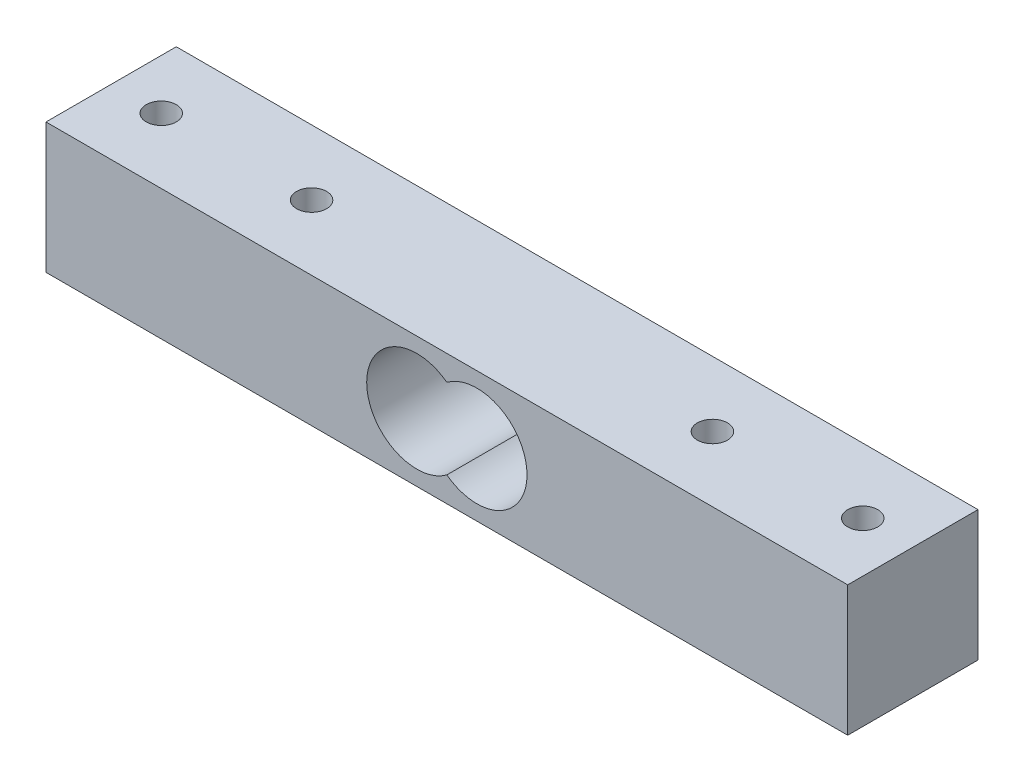
from build123d import *

# Parameters (mm, degrees)
SKETCH1_W               = 80
SKETCH1_H               = 13
BOSS_EXTRUDE1_DEPTH     = 13
CUT_EXTRUDE1_DEPTH      = 7.5
CUT_EXTRUDE1_DEPTH_BACK = 7.5
CUT_EXTRUDE2_REACH      = 15
SKETCH4_R               = 1.5


with BuildPart() as part:
    # Sketch1 → Boss-Extrude1 (new body)
    with BuildSketch(Plane(origin=(0, 0, 0), x_dir=(1, 0, 0), z_dir=(0, 1, 0))):
        Rectangle(SKETCH1_W, SKETCH1_H)
    extrude(amount=BOSS_EXTRUDE1_DEPTH)

    # Sketch3 → Cut-Extrude1 (cut, two sides)
    with BuildSketch(Plane.XY) as cut_extrude1_sk:
        with BuildLine():
            ThreePointArc((0, 2.5), (8, 6.5), (0, 10.5))
            ThreePointArc((0, 10.5), (-8, 6.5), (0, 2.5))
        make_face()
    extrude(amount=CUT_EXTRUDE1_DEPTH, mode=Mode.SUBTRACT)
    extrude(cut_extrude1_sk.sketch, amount=-CUT_EXTRUDE1_DEPTH_BACK, mode=Mode.SUBTRACT)

    # Sketch4 → Cut-Extrude2 (cut, up to next)
    with BuildSketch(Plane(origin=(0, 13, 0), x_dir=(1, 0, 0), z_dir=(0, 1, 0)), mode=Mode.PRIVATE) as cut_extrude2_sk1:
        with Locations((-35, 0)):
            Circle(SKETCH4_R)
    cut_extrude2_tool1 = extrude(cut_extrude2_sk1.sketch, amount=-CUT_EXTRUDE2_REACH, mode=Mode.PRIVATE) & part.part
    add(cut_extrude2_tool1.solids().sort_by_distance((-35, 13, 0))[0], mode=Mode.SUBTRACT)
    # Sketch4 → Cut-Extrude2 (cut, up to next)
    with BuildSketch(Plane(origin=(0, 13, 0), x_dir=(1, 0, 0), z_dir=(0, 1, 0)), mode=Mode.PRIVATE) as cut_extrude2_sk2:
        with Locations((-20, 0)):
            Circle(SKETCH4_R)
    cut_extrude2_tool2 = extrude(cut_extrude2_sk2.sketch, amount=-CUT_EXTRUDE2_REACH, mode=Mode.PRIVATE) & part.part
    add(cut_extrude2_tool2.solids().sort_by_distance((-20, 13, 0))[0], mode=Mode.SUBTRACT)
    # Sketch4 → Cut-Extrude2 (cut, up to next)
    with BuildSketch(Plane(origin=(0, 13, 0), x_dir=(1, 0, 0), z_dir=(0, 1, 0)), mode=Mode.PRIVATE) as cut_extrude2_sk3:
        with Locations((20, 0)):
            Circle(SKETCH4_R)
    cut_extrude2_tool3 = extrude(cut_extrude2_sk3.sketch, amount=-CUT_EXTRUDE2_REACH, mode=Mode.PRIVATE) & part.part
    add(cut_extrude2_tool3.solids().sort_by_distance((20, 13, 0))[0], mode=Mode.SUBTRACT)
    # Sketch4 → Cut-Extrude2 (cut, up to next)
    with BuildSketch(Plane(origin=(0, 13, 0), x_dir=(1, 0, 0), z_dir=(0, 1, 0)), mode=Mode.PRIVATE) as cut_extrude2_sk4:
        with Locations((35, 0)):
            Circle(SKETCH4_R)
    cut_extrude2_tool4 = extrude(cut_extrude2_sk4.sketch, amount=-CUT_EXTRUDE2_REACH, mode=Mode.PRIVATE) & part.part
    add(cut_extrude2_tool4.solids().sort_by_distance((35, 13, 0))[0], mode=Mode.SUBTRACT)


solid = part.part
